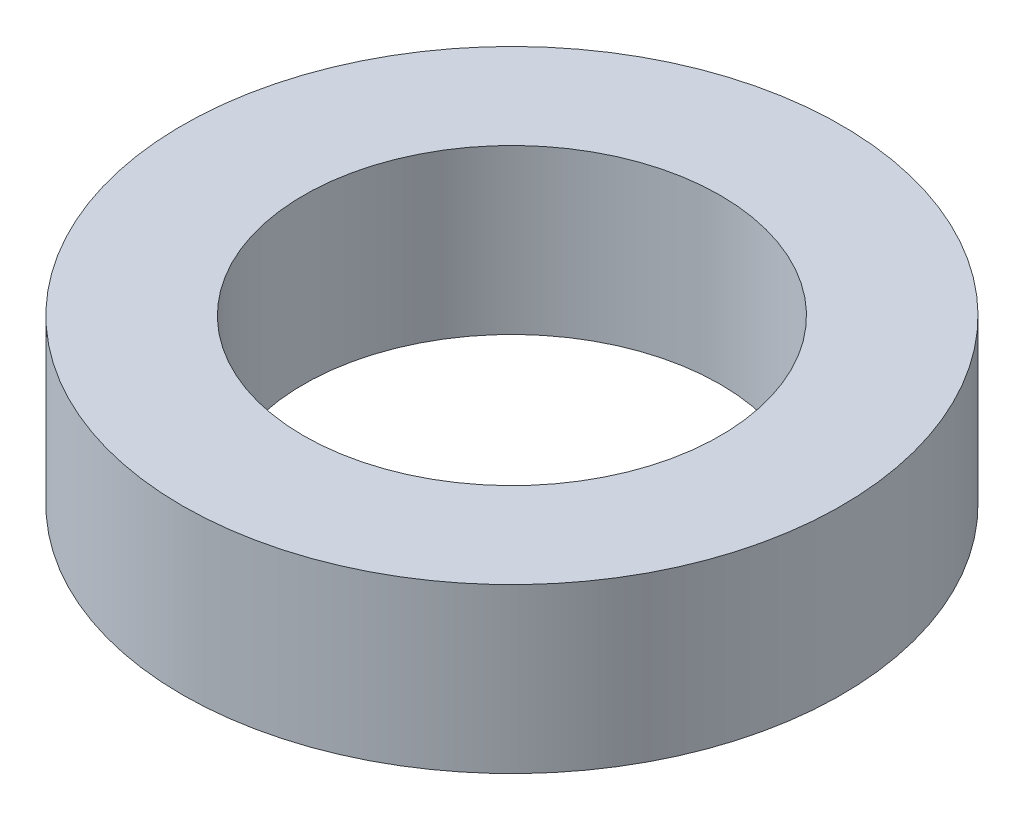
from build123d import *

# Parameters (mm, degrees)
SKETCH1_R           = 11.075
BOSS_EXTRUDE1_DEPTH = 5.5
SKETCH2_R           = 7
CUT_EXTRUDE1_DEPTH  = 5.5


with BuildPart() as part:
    # Sketch1 → Boss-Extrude1 (new body)
    with BuildSketch(Plane(origin=(0, 0, 0), x_dir=(1, 0, 0), z_dir=(0, 1, 0))):
        Circle(SKETCH1_R)
    extrude(amount=BOSS_EXTRUDE1_DEPTH)

    # Sketch2 → Cut-Extrude1 (cut)
    with BuildSketch(Plane(origin=(0, 5.5, 0), x_dir=(1, 0, 0), z_dir=(0, 1, 0))):
        Circle(SKETCH2_R)
    extrude(amount=-CUT_EXTRUDE1_DEPTH, mode=Mode.SUBTRACT)


solid = part.part
